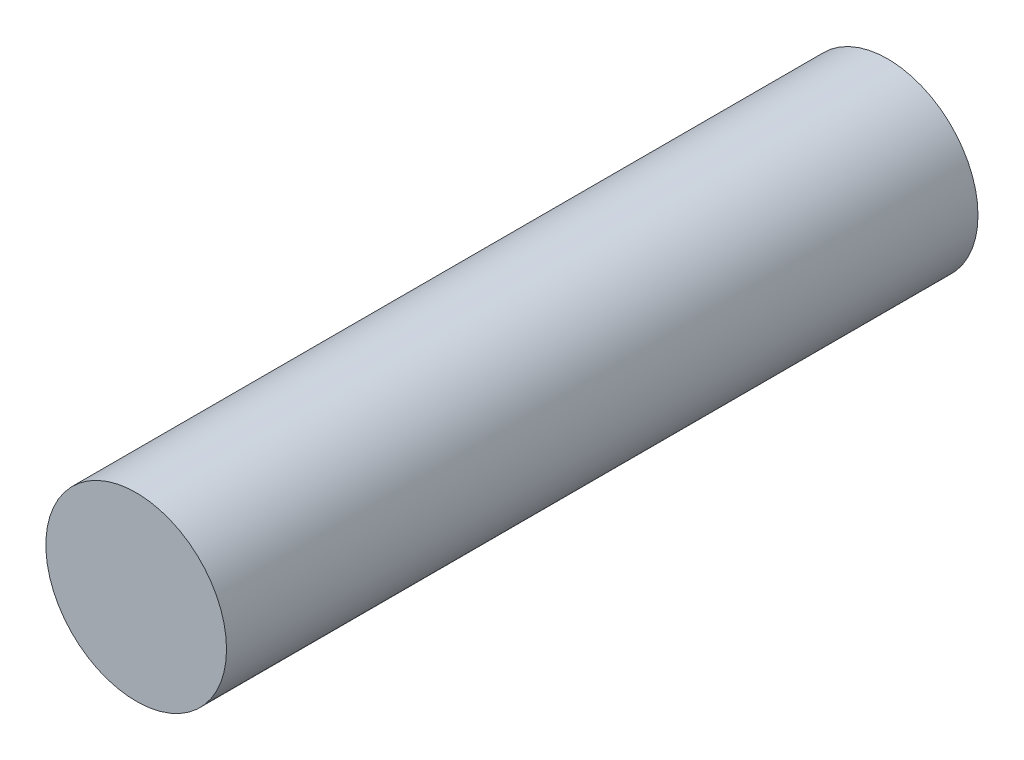
from build123d import *

# Parameters (mm, degrees)
SKETCH1_R           = 17.526
BOSS_EXTRUDE1_DEPTH = 145.779956598


with BuildPart() as part:
    # Sketch1 → Boss-Extrude1 (new body)
    with BuildSketch(Plane.XY):
        Circle(SKETCH1_R)
    extrude(amount=BOSS_EXTRUDE1_DEPTH)


solid = part.part
